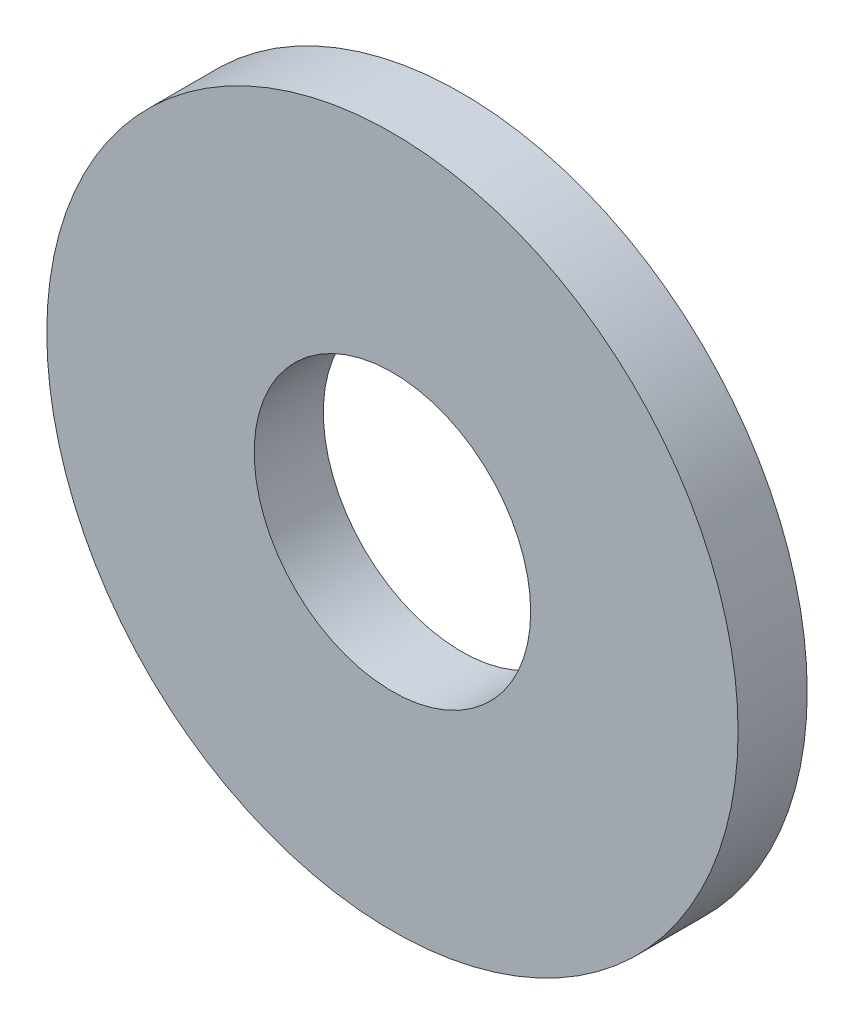
from build123d import *

# Parameters (mm, degrees)
SKETCH3_R           = 4
SKETCH3_R_2         = 1.6
BOSS_EXTRUDE1_DEPTH = 0.4


with BuildPart() as part:
    # Sketch3 → Boss-Extrude1 (new body, symmetric)
    with BuildSketch(Plane.XY):
        Circle(SKETCH3_R)
        Circle(SKETCH3_R_2, mode=Mode.SUBTRACT)
    extrude(amount=BOSS_EXTRUDE1_DEPTH, both=True)


solid = part.part
